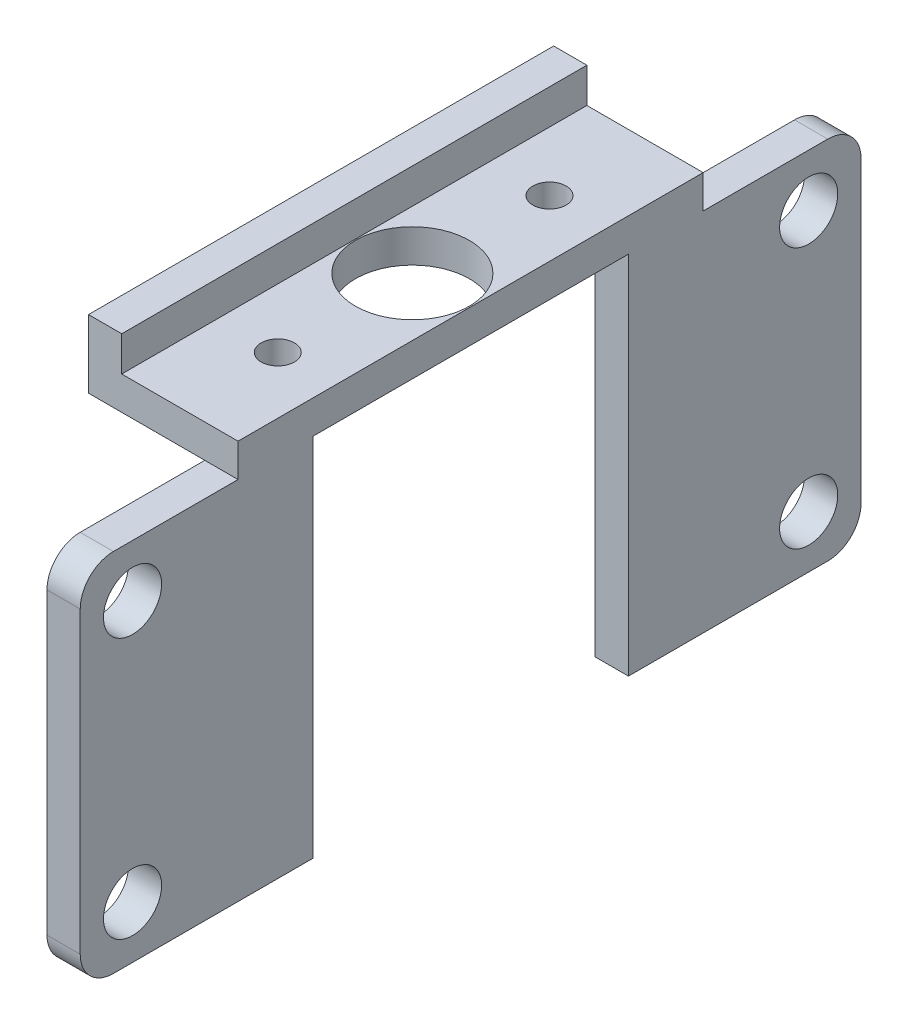
from build123d import *

# Parameters (mm, degrees)
BOSS_EXTRUDE3_DEPTH = 28
SKETCH4_R           = 3.43
SKETCH4_R_2         = 1
CUT_EXTRUDE1_DEPTH  = 2
SKETCH6_W           = 2
SKETCH6_H           = 22
BOSS_EXTRUDE4_DEPTH = 9.5
SKETCH7_W           = 2
SKETCH7_H           = 22
BOSS_EXTRUDE5_DEPTH = 9.5
FILLET1_R           = 2
FILLET2_R           = 2
FILLET3_R           = 2
CUT_EXTRUDE2_REACH  = 4
SKETCH8_R           = 1.75
CUT_EXTRUDE3_REACH  = 11
SKETCH9_W           = 19
SKETCH9_H           = 22


with BuildPart() as part:
    # Sketch3 → Boss-Extrude3 (new body)
    with BuildSketch(Plane.XY):
        Polygon((-16.953175304, 6.6875), (-14.953175304, 6.6875), (-14.953175304, 4.5875), (-7.953175304, 4.5875), (-7.953175304, -19.4125), (-9.953175304, -19.4125), (-9.953175304, 2.5875), (-16.953175304, 2.5875), align=None)
    extrude(amount=BOSS_EXTRUDE3_DEPTH)

    # Sketch4 → Cut-Extrude1 (cut)
    with BuildSketch(Plane(origin=(0, 4.5875, 0), x_dir=(1, 0, 0), z_dir=(0, 1, 0))):
        with Locations((-11.458423587, -14)):
            Circle(SKETCH4_R)
        with Locations((-11.383175304, -5.822)):
            Circle(SKETCH4_R_2)
        with Locations((-11.383175304, -22.177653801)):
            Circle(SKETCH4_R_2)
    extrude(amount=-CUT_EXTRUDE1_DEPTH, mode=Mode.SUBTRACT)

    # Sketch6 → Boss-Extrude4 (add)
    with BuildSketch(Plane(origin=(0, 0, 0), x_dir=(-1, 0, 0), z_dir=(0, 0, -1))):
        with Locations((8.953175304, -8.4125)):
            Rectangle(SKETCH6_W, SKETCH6_H)
    extrude(amount=BOSS_EXTRUDE4_DEPTH)

    # Sketch7 → Boss-Extrude5 (add)
    with BuildSketch(Plane.XY.offset(28)):
        with Locations((-8.953175304, -8.4125)):
            Rectangle(SKETCH7_W, SKETCH7_H)
    extrude(amount=BOSS_EXTRUDE5_DEPTH)

    # Fillet1
    fillet1_edges = [part.edges().sort_by_distance(p)[0] for p in [
        (-8.953175304, 2.5875, 37.5),
    ]]
    fillet(fillet1_edges, radius=FILLET1_R)

    # Fillet2
    fillet2_edges = [part.edges().sort_by_distance(p)[0] for p in [
        (-8.953175304, 2.5875, -9.5),
    ]]
    fillet(fillet2_edges, radius=FILLET2_R)

    # Fillet3
    fillet3_edges = [part.edges().sort_by_distance(p)[0] for p in [
        (-8.953175304, -19.4125, -9.5),
        (-8.953175304, -19.4125, 37.5),
    ]]
    fillet(fillet3_edges, radius=FILLET3_R)

    # Sketch8 → Cut-Extrude2 (cut, up to next)
    with BuildSketch(Plane.ZY.offset(9.953175304), mode=Mode.PRIVATE) as cut_extrude2_sk1:
        with Locations((34.35, -0.5625)):
            Circle(SKETCH8_R)
    cut_extrude2_tool1 = extrude(cut_extrude2_sk1.sketch, amount=-CUT_EXTRUDE2_REACH, mode=Mode.PRIVATE) & part.part
    add(cut_extrude2_tool1.solids().sort_by_distance((-9.953175, -0.5625, 34.35))[0], mode=Mode.SUBTRACT)
    # Sketch8 → Cut-Extrude2 (cut, up to next)
    with BuildSketch(Plane.ZY.offset(9.953175304), mode=Mode.PRIVATE) as cut_extrude2_sk2:
        with Locations((-6.35, -0.5625)):
            Circle(SKETCH8_R)
    cut_extrude2_tool2 = extrude(cut_extrude2_sk2.sketch, amount=-CUT_EXTRUDE2_REACH, mode=Mode.PRIVATE) & part.part
    add(cut_extrude2_tool2.solids().sort_by_distance((-9.953175, -0.5625, -6.35))[0], mode=Mode.SUBTRACT)
    # Sketch8 → Cut-Extrude2 (cut, up to next)
    with BuildSketch(Plane.ZY.offset(9.953175304), mode=Mode.PRIVATE) as cut_extrude2_sk3:
        with Locations((-6.35, -16.2625)):
            Circle(SKETCH8_R)
    cut_extrude2_tool3 = extrude(cut_extrude2_sk3.sketch, amount=-CUT_EXTRUDE2_REACH, mode=Mode.PRIVATE) & part.part
    add(cut_extrude2_tool3.solids().sort_by_distance((-9.953175, -16.2625, -6.35))[0], mode=Mode.SUBTRACT)
    # Sketch8 → Cut-Extrude2 (cut, up to next)
    with BuildSketch(Plane.ZY.offset(9.953175304), mode=Mode.PRIVATE) as cut_extrude2_sk4:
        with Locations((34.35, -16.2625)):
            Circle(SKETCH8_R)
    cut_extrude2_tool4 = extrude(cut_extrude2_sk4.sketch, amount=-CUT_EXTRUDE2_REACH, mode=Mode.PRIVATE) & part.part
    add(cut_extrude2_tool4.solids().sort_by_distance((-9.953175, -16.2625, 34.35))[0], mode=Mode.SUBTRACT)

    # Sketch9 → Cut-Extrude3 (cut, up to next)
    with BuildSketch(Plane(origin=(-7.953175304, 0, 0), x_dir=(0, 0, -1), z_dir=(1, 0, 0)), mode=Mode.PRIVATE) as cut_extrude3_sk1:
        with Locations((-14, -8.4125)):
            Rectangle(SKETCH9_W, SKETCH9_H)
    cut_extrude3_tool1 = extrude(cut_extrude3_sk1.sketch, amount=-CUT_EXTRUDE3_REACH, mode=Mode.PRIVATE) & part.part
    add(cut_extrude3_tool1.solids().sort_by_distance((-7.953175, -8.4125, 14))[0], mode=Mode.SUBTRACT)


solid = part.part
